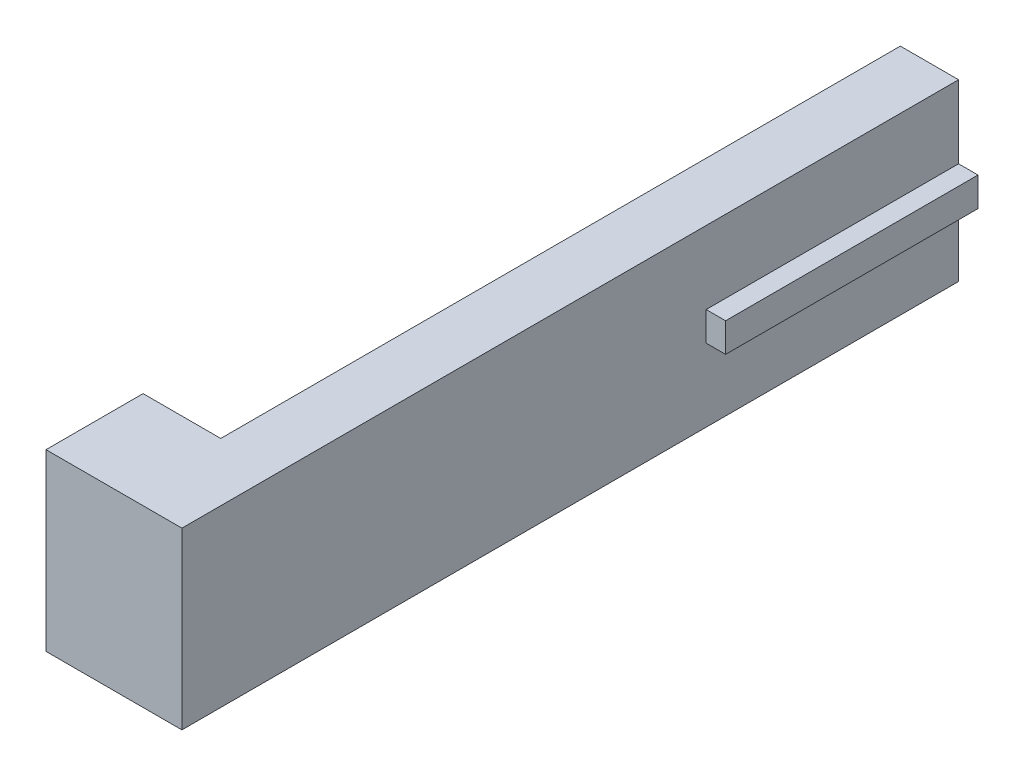
from build123d import *

# Parameters (mm, degrees)
BOSS_EXTRUDE3_DEPTH = 200
SKETCH5_W           = 135
SKETCH5_H           = 7.5
CUT_EXTRUDE1_DEPTH  = 5
SKETCH6_W           = 20
SKETCH6_H           = 45
BOSS_EXTRUDE4_DEPTH = 25
SKETCH7_W           = 5
SKETCH7_H           = 7.5
CUT_EXTRUDE2_DEPTH  = 175


with BuildPart() as part:
    # Sketch4 → Boss-Extrude3 (new body)
    with BuildSketch(Plane.XY):
        Polygon((5, -3.75), (0, -3.75), (0, -22.5), (-15, -22.5), (-15, 22.5), (0, 22.5), (0, 3.75), (5, 3.75), align=None)
    extrude(amount=BOSS_EXTRUDE3_DEPTH)

    # Sketch5 → Cut-Extrude1 (cut)
    with BuildSketch(Plane(origin=(5, 0, 0), x_dir=(0, 0, -1), z_dir=(1, 0, 0))):
        with Locations((-132.5, 0)):
            Rectangle(SKETCH5_W, SKETCH5_H)
    extrude(amount=-CUT_EXTRUDE1_DEPTH, mode=Mode.SUBTRACT)

    # Sketch6 → Boss-Extrude4 (add)
    with BuildSketch(Plane.XY.offset(200)):
        with Locations((-25, 0)):
            Rectangle(SKETCH6_W, SKETCH6_H)
    extrude(amount=-BOSS_EXTRUDE4_DEPTH)

    # Sketch7 → Cut-Extrude2 (cut)
    with BuildSketch(Plane(origin=(0, 0, 0), x_dir=(-1, 0, 0), z_dir=(0, 0, -1))):
        with Locations((12.5, 0)):
            Rectangle(SKETCH7_W, SKETCH7_H)
    extrude(amount=-CUT_EXTRUDE2_DEPTH, mode=Mode.SUBTRACT)


solid = part.part
